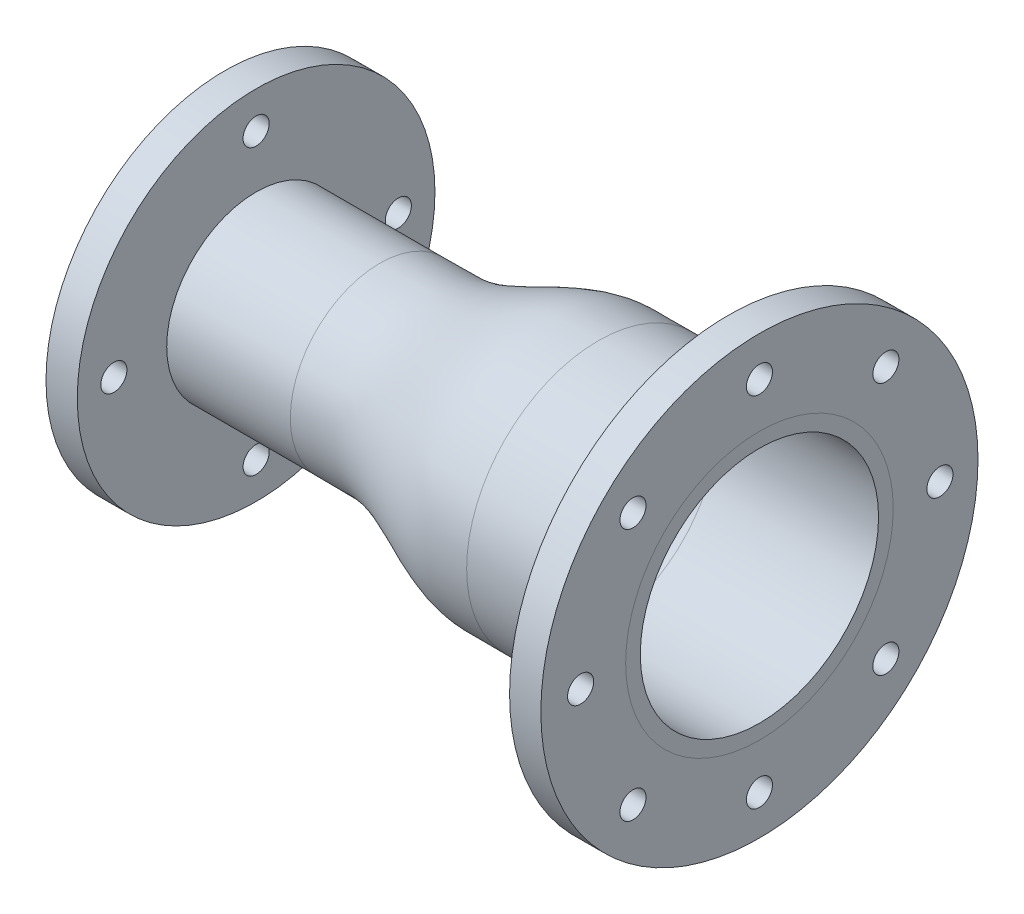
from build123d import *

# Parameters (mm, degrees)
F_5_8_CLEARANCE_HOLE1_D                             = 16.66748
F_5_8_CLEARANCE_HOLE1_DEPTH                         = 20
CSK_FOR_5_8_FLAT_HEAD_MACHINE_SCREW_100_D           = 16.66748
CSK_FOR_5_8_FLAT_HEAD_MACHINE_SCREW_100_DEPTH       = 20
CSK_FOR_5_8_FLAT_HEAD_MACHINE_SCREW_100_CSINK_D     = 32.3088
CSK_FOR_5_8_FLAT_HEAD_MACHINE_SCREW_100_CSINK_ANGLE = 100


with BuildPart() as part:
    # Sketch2 → Revolve1 (revolve)
    with BuildSketch(Plane.XY):
        with BuildLine():
            Line((341.7, 76.137499212), (341.7, 139.7))
            Line((341.7, 139.7), (321.7, 139.7))
            Line((321.7, 139.7), (321.7, 84.137499212))
            Line((321.7, 84.137499212), (238.7, 84.137499212))
            add(Edge.make_bspline(
                [(238.7, 84.137499212), (238.355924075, 84.137499212), (237.667772223, 84.137499211), (236.43892963, 84.137499212), (234.866011112, 84.137499209), (233.096477778, 84.137499221), (231.179483334, 84.137499181), (229.409949997, 84.137499346), (227.492955565, 84.137498785), (225.723422181, 84.137501116), (223.806427909, 84.137493202), (222.03689386, 84.137526067), (220.119901847, 84.137414453), (218.350358415, 84.137877999), (216.436180482, 84.136306025), (214.671251811, 84.142808495), (212.761120781, 84.086749305), (210.997970421, 83.981894478), (209.088061418, 83.811610968), (207.325068085, 83.603702947), (205.415339805, 83.325577691), (203.652528826, 83.021476856), (201.742980231, 82.643054651), (199.980349522, 82.250081454), (198.070973132, 81.779589057), (196.308510241, 81.305636666), (194.399291637, 80.751921317), (192.636978054, 80.205434277), (190.727898375, 79.577923288), (188.965712472, 78.967858654), (187.056750607, 78.276511422), (185.294669761, 77.61229035), (183.385803915, 76.867540678), (181.623805854, 76.15899109), (179.715014471, 75.371680114), (177.95307795, 74.628970979), (176.044340155, 73.810271455), (174.28244512, 73.043839656), (172.373740784, 72.205172954), (170.611868192, 71.425644088), (168.701772289, 70.577967809), (166.937395899, 69.794959659), (165.024786727, 68.949453647), (163.259291454, 68.174390413), (161.346657228, 67.343861664), (159.58112861, 66.587981326), (157.668449277, 65.784003027), (155.902867536, 65.057899506), (153.990122343, 64.291832507), (152.22446654, 63.60586364), (150.311633974, 62.888769921), (148.545882008, 62.252980739), (146.632940071, 61.595543531), (144.867069113, 61.019596499), (142.95399603, 60.432048638), (141.187983586, 59.925161995), (139.274759098, 59.417223546), (137.508584813, 58.988118492), (135.595192141, 58.568944237), (133.828840435, 58.225800875), (131.915268777, 57.903938632), (130.148732425, 57.654357312), (128.234978669, 57.437727635), (126.468267149, 57.288649922), (124.789582716, 57.197477456), (123.443760708, 57.156958736), (122.420535806, 57.149027418), (121.677966993, 57.150148752), (120.601758891, 57.149831794), (119.202172332, 57.150049881), (117.285177742, 57.149983489), (115.515644452, 57.150003038), (113.598649997, 57.149998331), (111.829116667, 57.149999717), (109.912122221, 57.149999383), (108.142588888, 57.149999482), (106.225594444, 57.149999458), (104.45606111, 57.149999465), (102.539066666, 57.149999463), (101.039878703, 57.149999464), (99.81103611, 57.149999464), (99.27034537, 57.149999464), (98.999999999, 57.149999464)],
                knots=[0, 0, 0, 0, 0.007154165, 0.014308329, 0.025550588, 0.039858917, 0.051101176, 0.065409505, 0.076651764, 0.090960094, 0.102202352, 0.116510682, 0.12775294, 0.14206127, 0.153303528, 0.167554008, 0.178755429, 0.193030915, 0.204271905, 0.218620642, 0.229935227, 0.24439542, 0.255809505, 0.270408809, 0.281939941, 0.296695409, 0.308352907, 0.323271342, 0.335056718, 0.350135378, 0.362042998, 0.377270556, 0.389288475, 0.404646168, 0.416757099, 0.432220021, 0.44440238, 0.459940864, 0.472169892, 0.487750951, 0.499999862, 0.51562065, 0.52788688, 0.543480107, 0.55571106, 0.571242545, 0.583412274, 0.598850533, 0.610935794, 0.626253518, 0.638234915, 0.653410393, 0.66527347, 0.680291945, 0.692028204, 0.706883096, 0.718490902, 0.733184872, 0.744670204, 0.75921598, 0.770592966, 0.785013865, 0.796305044, 0.810635098, 0.821871343, 0.831256632, 0.838627865, 0.843146285, 0.846696472, 0.861004801, 0.87224706, 0.886555389, 0.897797648, 0.912105977, 0.923348236, 0.937656565, 0.948898824, 0.963207153, 0.974449412, 0.988757741, 0.994378871, 1, 1, 1, 1], degree=3, weights=[0.576132148, 0.576132148, 0.576132148, 0.576132148, 0.576132148, 0.576132148, 0.576132148, 0.576132148, 0.576132148, 0.576132148, 0.576132148, 0.576132148, 0.576132148, 0.576132148, 0.576132148, 0.576132148, 0.576132148, 0.576132148, 0.576132148, 0.576132148, 0.576132148, 0.576132148, 0.576132148, 0.576132148, 0.576132148, 0.576132148, 0.576132148, 0.576132148, 0.576132148, 0.576132148, 0.576132148, 0.576132148, 0.576132148, 0.576132148, 0.576132148, 0.576132148, 0.576132148, 0.576132148, 0.576132148, 0.576132148, 0.576132148, 0.576132148, 0.576132148, 0.576132148, 0.576132148, 0.576132148, 0.576132148, 0.576132148, 0.576132148, 0.576132148, 0.576132148, 0.576132148, 0.576132148, 0.576132148, 0.576132148, 0.576132148, 0.576132148, 0.576132148, 0.576132148, 0.576132148, 0.576132148, 0.576132148, 0.576132148, 0.576132148, 0.576132148, 0.576132148, 0.576132148, 0.576132148, 0.576132148, 0.576132148, 0.576132148, 0.576132148, 0.576132148, 0.576132148, 0.576132148, 0.576132148, 0.576132148, 0.576132148, 0.576132148, 0.576132148, 0.576132148, 0.576132148, 0.576132148]))
            Line((98.999999999, 57.149999464), (20, 57.149999464))
            Line((20, 57.149999464), (20, 114.3))
            Line((20, 114.3), (0, 114.3))
            Line((0, 114.3), (0, 49.149999464))
            Line((0, 49.149999464), (98.999999999, 49.149999464))
            add(Edge.make_bspline(
                [(238.700000001, 76.137499212), (235.69409428, 76.137499211), (231.185175342, 76.137529978), (225.92498116, 76.137458281), (222.918904328, 76.137568327), (220.664664612, 76.137283149), (218.784669959, 76.138023248), (217.290602157, 76.13677783), (216.128457097, 76.1382361), (215.066881493, 76.138852647), (213.792519107, 76.118938664), (211.496695076, 76.015652057), (208.229301379, 75.6893674), (204.270612611, 75.027164667), (200.298712296, 74.120693109), (194.985358164, 72.623109637), (188.321466773, 70.283294689), (180.275439823, 66.96143105), (172.126179657, 63.34551056), (163.790302615, 59.64532736), (155.164556548, 56.079333574), (147.64132386, 53.429737774), (141.378908996, 51.662061148), (136.556364248, 50.559794229), (131.615917341, 49.730227773), (127.403841781, 49.309288048), (124.437765649, 49.174559905), (122.930150126, 49.151400947), (122.100741829, 49.149426118), (121.356980871, 49.150399773), (120.417271001, 49.149754665), (118.913072261, 49.150117503), (117.035873074, 49.149952223), (114.780889972, 49.150013449), (111.775161973, 49.149990987), (106.514717734, 49.150005821), (102.005905795, 49.149999464), (98.999999999, 49.149999464)],
                knots=[0, 0, 0, 0, 0.0625, 0.09375, 0.109375, 0.125, 0.140625, 0.1484375, 0.15625, 0.1640625, 0.171875, 0.1875, 0.21875, 0.25, 0.28125, 0.3125, 0.375, 0.4375, 0.5, 0.5625, 0.625, 0.6875, 0.71875, 0.75, 0.78125, 0.8125, 0.828125, 0.8359375, 0.83984375, 0.84375, 0.8515625, 0.859375, 0.875, 0.890625, 0.90625, 0.9375, 1, 1, 1, 1], degree=3))
            Line((238.700000001, 76.137499212), (341.7, 76.137499212))
        make_face()
    revolve(axis=Axis((341.7, 0, 0), (-1, 0, 0)))

    # 5/8 Clearance Hole1
    with Locations(Plane(origin=(0, -86.94526051, 61.229912904), x_dir=(0, 0, 1), z_dir=(-1, 0, 0))):
        with Locations((-61.229912904, 177.798020209), (29.681467244, 86.94526051), (-61.229912904, -3.966119638), (-152.141293051, 86.94526051)):
            Hole(F_5_8_CLEARANCE_HOLE1_D / 2, depth=F_5_8_CLEARANCE_HOLE1_DEPTH)

    # CSK for 5_8 Flat Head Machine Screw _100
    with Locations(Plane(origin=(321.7, -86.94526051, 61.229912904), x_dir=(0, 0, 1), z_dir=(-1, 0, 0))):
        with Locations((-61.229912904, 201.24526051), (-176.596487394, 86.94526051), (-142.052217993, 167.767565599), (19.592392186, 167.767565599), (53.070087096, 86.94526051), (19.592392186, 6.12295542), (-61.229912904, -27.406492985), (-142.052217993, 6.12295542)):
            CounterSinkHole(CSK_FOR_5_8_FLAT_HEAD_MACHINE_SCREW_100_D / 2, CSK_FOR_5_8_FLAT_HEAD_MACHINE_SCREW_100_CSINK_D / 2, depth=CSK_FOR_5_8_FLAT_HEAD_MACHINE_SCREW_100_DEPTH, counter_sink_angle=CSK_FOR_5_8_FLAT_HEAD_MACHINE_SCREW_100_CSINK_ANGLE)


solid = part.part
